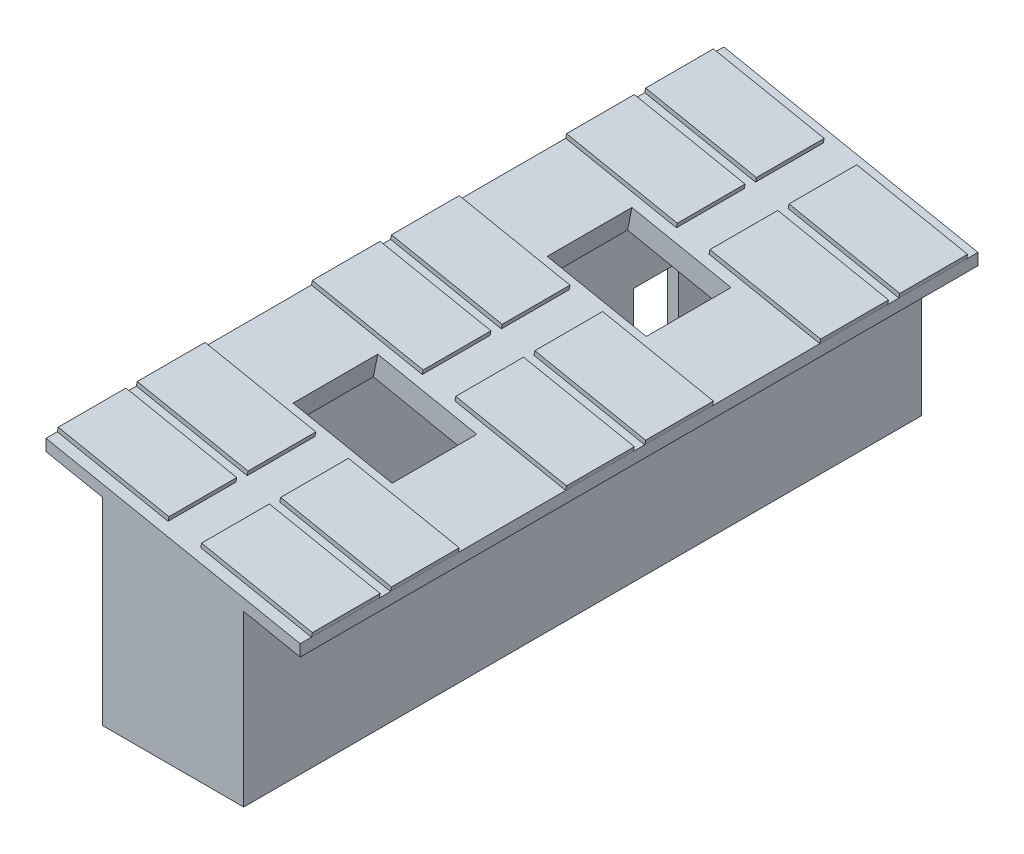
from build123d import *

# Parameters (mm, degrees)
BOSS_EXTRUDE1_DEPTH = 12000
SKETCH2_W           = 2000
SKETCH2_H           = 1200
BOSS_EXTRUDE2_DEPTH = 80
SKETCH3_W           = 1789.117562234
SKETCH3_H           = 1500
CUT_EXTRUDE1_DEPTH  = 400
BOSS_EXTRUDE3_DEPTH = 200
BOSS_EXTRUDE4_DEPTH = 200
SKETCH6_W           = 800
SKETCH6_H           = 2000
CUT_EXTRUDE2_DEPTH  = 200
SKETCH7_W           = 11600
SKETCH7_H           = 60
BOSS_EXTRUDE5_DEPTH = 800
SKETCH8_R           = 100
SKETCH8_R_2         = 70
BOSS_EXTRUDE7_DEPTH = 11721
SKETCH9_W           = 11600
SKETCH9_H           = 1000
BOSS_EXTRUDE8_DEPTH = 20


with BuildPart() as part:
    # Sketch1 → Boss-Extrude1 (new body)
    with BuildSketch(Plane.XY):
        Polygon((2500, -3500), (2500, -500), (0, 0), (0, -3500), align=None)
        Polygon((2300, -663.960780544), (200, -236.33182537), (200, -3300), (2300, -3300), align=None, mode=Mode.SUBTRACT)
        Polygon((-1000, 200), (0, 0), (2500, -500), (3500, -700), (3500, -496.039219456), (-1000, 403.960780544), align=None)
    extrude(amount=BOSS_EXTRUDE1_DEPTH)

    # Sketch2 → Boss-Extrude2 (add)
    with BuildSketch(Plane(origin=(39.223227028, 196.116135138, 0), x_dir=(0.9805806756909202, -0.19611613513818382, 0), z_dir=(0.19611613513818382, 0.9805806756909203, 0))):
        with Locations((-59.803902719, -11200)):
            Rectangle(SKETCH2_W, SKETCH2_H)
        with Locations((2529.313659515, -11200)):
            Rectangle(SKETCH2_W, SKETCH2_H)
        with Locations((-59.803902719, -9800)):
            Rectangle(SKETCH2_W, SKETCH2_H)
        with Locations((2529.313659515, -9800)):
            Rectangle(SKETCH2_W, SKETCH2_H)
        with Locations((-59.803902719, -6700)):
            Rectangle(SKETCH2_W, SKETCH2_H)
        with Locations((2529.313659515, -6700)):
            Rectangle(SKETCH2_W, SKETCH2_H)
        with Locations((-59.803902719, -800)):
            Rectangle(SKETCH2_W, SKETCH2_H)
        with Locations((2529.313659515, -800)):
            Rectangle(SKETCH2_W, SKETCH2_H)
        with Locations((-59.803902719, -2200)):
            Rectangle(SKETCH2_W, SKETCH2_H)
        with Locations((-59.803902719, -5300)):
            Rectangle(SKETCH2_W, SKETCH2_H)
        with Locations((2529.313659515, -2200)):
            Rectangle(SKETCH2_W, SKETCH2_H)
        with Locations((2529.313659515, -5300)):
            Rectangle(SKETCH2_W, SKETCH2_H)
    extrude(amount=BOSS_EXTRUDE2_DEPTH)

    # Sketch3 → Cut-Extrude1 (cut)
    with BuildSketch(Plane(origin=(39.223227028, 196.116135138, 0), x_dir=(0.9805806756909202, -0.19611613513818382, 0), z_dir=(0.19611613513818382, 0.9805806756909203, 0))):
        with Locations((1234.754878398, -8250)):
            Rectangle(SKETCH3_W, SKETCH3_H)
        with Locations((1234.754878398, -3750)):
            Rectangle(SKETCH3_W, SKETCH3_H)
    extrude(amount=-CUT_EXTRUDE1_DEPTH, mode=Mode.SUBTRACT)

    # Sketch4 → Boss-Extrude3 (add)
    with BuildSketch(Plane.XY.offset(12000)):
        Polygon((2500, -3500), (2500, -500), (3500, -700), (3500, -496.039219456), (-1000, 403.960780544), (-1000, 200), (0, 0), (0, -3500), align=None)
    extrude(amount=-BOSS_EXTRUDE3_DEPTH)

    # Sketch5 → Boss-Extrude4 (add)
    with BuildSketch(Plane(origin=(0, 0, 0), x_dir=(-1, 0, 0), z_dir=(0, 0, -1))):
        Polygon((-2500, -500), (-2500, -3500), (0, -3500), (0, 0), (1000, 200), (1000, 403.960780544), (-3500, -496.039219456), (-3500, -700), align=None)
    extrude(amount=-BOSS_EXTRUDE4_DEPTH)

    # Sketch6 → Cut-Extrude2 (cut)
    with BuildSketch(Plane.ZY):
        with Locations((2400, -2300)):
            Rectangle(SKETCH6_W, SKETCH6_H)
        with Locations((9600, -2300)):
            Rectangle(SKETCH6_W, SKETCH6_H)
    extrude(amount=-CUT_EXTRUDE2_DEPTH, mode=Mode.SUBTRACT)

    # Sketch7 → Boss-Extrude5 (add)
    with BuildSketch(Plane.ZY.offset(-2300)):
        with Locations((6000, -2610)):
            Rectangle(SKETCH7_W, SKETCH7_H)
    extrude(amount=BOSS_EXTRUDE5_DEPTH)

    # Sketch8 → Boss-Extrude7 (add)
    with BuildSketch(Plane(origin=(0, 0, 11800), x_dir=(-1, 0, 0), z_dir=(0, 0, -1))):
        with Locations(Location((-2180, -763.960780544, 0), (0, 0, 180))):
            Circle(SKETCH8_R)
        with Locations(Location((-2180, -763.960780544, 0), (0, 0, 180))):
            Circle(SKETCH8_R_2, mode=Mode.SUBTRACT)
    extrude(amount=BOSS_EXTRUDE7_DEPTH)

    # Sketch9 → Boss-Extrude8 (add)
    with BuildSketch(Plane.ZY.offset(-2300)):
        with Locations((6000, -1680)):
            Rectangle(SKETCH9_W, SKETCH9_H)
    extrude(amount=BOSS_EXTRUDE8_DEPTH)


solid = part.part
